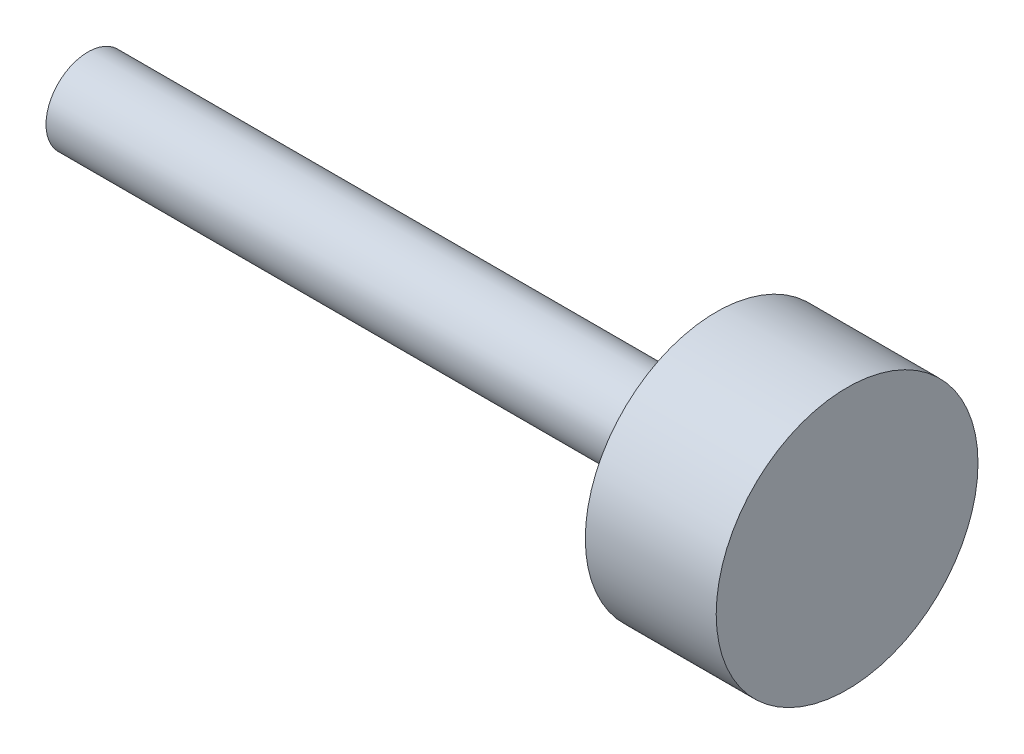
from build123d import *


with BuildPart() as part:
    # Sketch1 → Revolve1 (revolve)
    with BuildSketch(Plane.XY):
        Polygon((0, 0), (9.2075, 0), (9.2075, 1.5875), (7.62, 1.5875), (7.62, 0.508), (0, 0.508), align=None)
    revolve(axis=Axis((0, 0, 0), (1, 0, 0)))


solid = part.part
